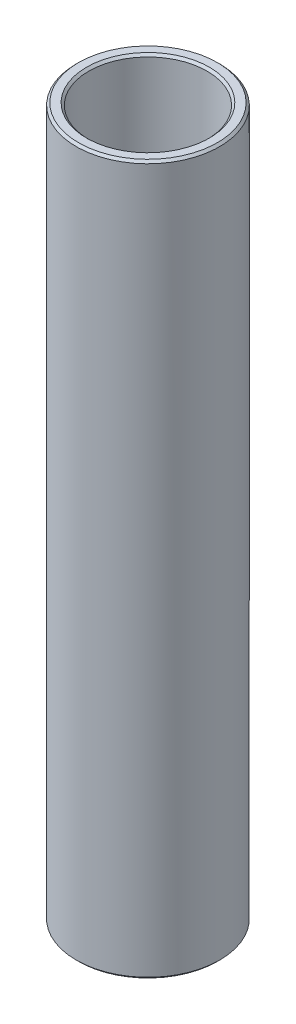
from build123d import *

# Parameters (mm, degrees)
SKETCH1_W     = 0.7
SKETCH1_H     = 39.55
CHAMFER1_SIZE = 0.127


with BuildPart() as part:
    # Sketch1 → Revolve1 (revolve)
    with BuildSketch(Plane.XY):
        with Locations((-3.65, 0)):
            Rectangle(SKETCH1_W, SKETCH1_H)
    revolve(axis=Axis((0, 19.775, 0), (0, -1, 0)))

    # Chamfer1
    chamfer1_edges = [part.edges().sort_by_distance(p)[0] for p in [
        (3.3, -19.775, 0),
        (4, -19.775, 0),
        (4, 19.775, 0),
        (3.3, 19.775, 0),
    ]]
    chamfer(chamfer1_edges, length=CHAMFER1_SIZE)


solid = part.part
